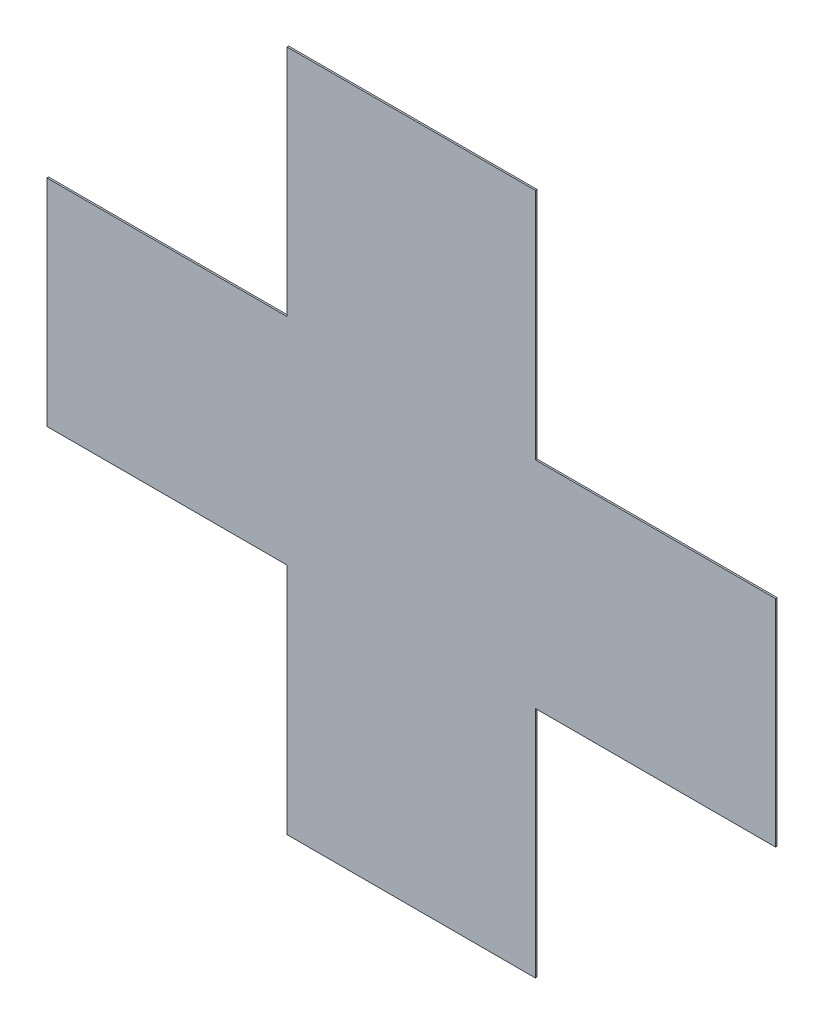
from build123d import *

# Parameters (mm, degrees)
BOSS_EXTRUDE1_DEPTH = 2


with BuildPart() as part:
    # Sketch1 → Boss-Extrude1 (new body)
    with BuildSketch(Plane.XY):
        Polygon((-150, 412), (150, 412), (150, 130), (440, 130), (440, -130), (150, -130), (150, -412), (-150, -412), (-150, -130), (-440, -130), (-440, 130), (-150, 130), align=None)
    extrude(amount=BOSS_EXTRUDE1_DEPTH)


solid = part.part
